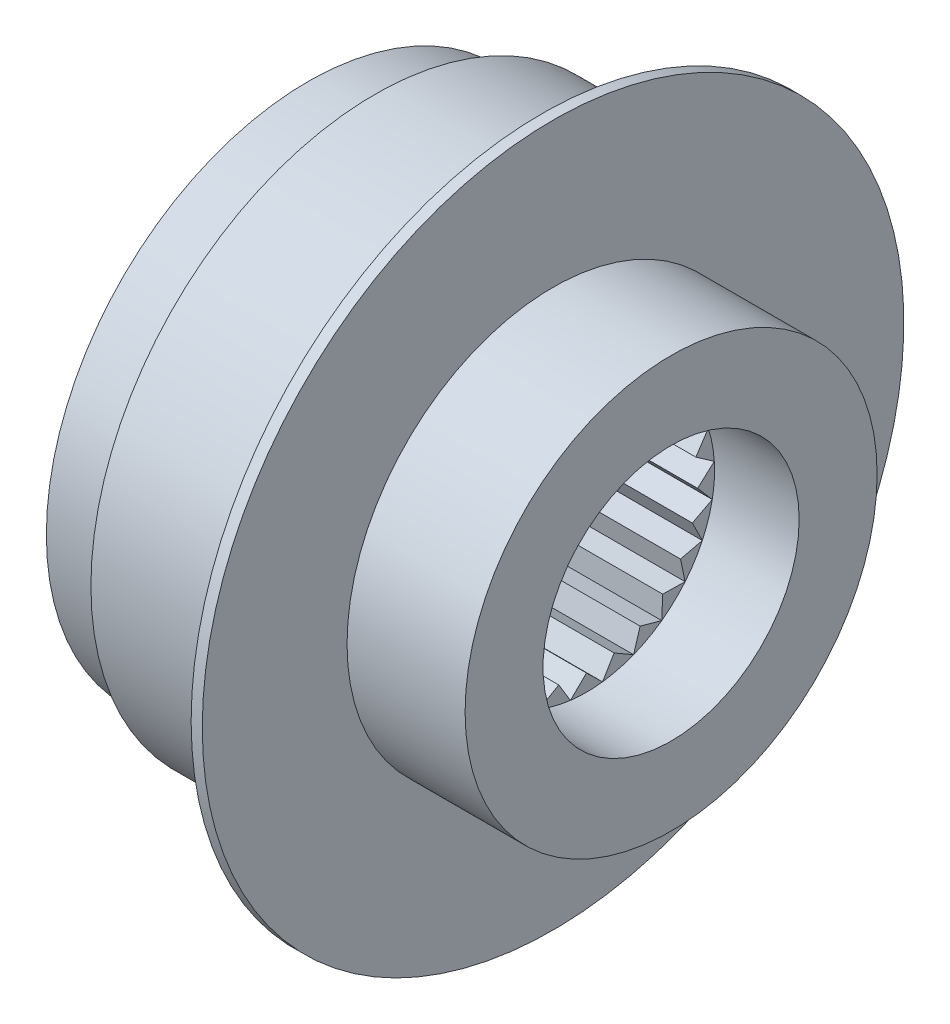
from build123d import *

# Parameters (mm, degrees)
SKETCH2_R          = 3.96875
CUT_EXTRUDE1_DEPTH = 6.35
CUT_EXTRUDE2_START = -41.402
CUT_EXTRUDE2_DEPTH = 31.75
SKETCH3_4_R        = 14.605
CUT_EXTRUDE3_DEPTH = 9.652


with BuildPart() as part:
    # Sketch1 → Revolve1 (revolve)
    with BuildSketch(Plane(origin=(0, 0, 0), x_dir=(1, 0, 0), z_dir=(0, 1, 0))):
        Polygon((-20.701, -12.7), (-20.701, -29.845), (-13.081, -29.845), (-13.081, -32.385), (5.969, -32.385), (5.969, -40.005), (7.239, -40.005), (7.239, -23.495), (20.701, -23.495), (20.701, -12.7), align=None)
    revolve(axis=Axis((-34.012862719, 0, 0), (1, 0, 0)))

    # Sketch2 → Cut-Extrude1 (cut)
    with BuildSketch(Plane(origin=(-20.701, 0, 0), x_dir=(0, 0, -1), z_dir=(1, 0, 0))):
        with Locations((22.225, 0)):
            Circle(SKETCH2_R)
        with Locations((-11.1125, -19.247414599)):
            Circle(SKETCH2_R)
        with Locations((-11.1125, 19.247414599)):
            Circle(SKETCH2_R)
    extrude(amount=CUT_EXTRUDE1_DEPTH, mode=Mode.SUBTRACT)

    # Sketch3 → Cut-Extrude2 (cut)
    with BuildSketch(Plane(origin=(20.701, 0, 0), x_dir=(0, 0, -1), z_dir=(1, 0, 0)).offset(CUT_EXTRUDE2_START)):
        with BuildLine():
            Line((-13.214999101, -6.218506553), (-10.722964654, -6.805000296))
            ThreePointArc((-10.722964654, -6.805000296), (-11.491303566, -5.407397003), (-12.078417757, -3.924515829))
            Line((-12.078417757, -3.924515829), (-13.214999101, -6.218506553))
        make_face()
        with BuildLine():
            Line((-14.346305297, -2.7367041), (-12.078417757, -3.924515829))
            ThreePointArc((-12.078417757, -3.924515829), (-12.475048084, -2.379742695), (-12.674939451, -0.797439598))
            Line((-12.674939451, -0.797439598), (-14.346305297, -2.7367041))
        make_face()
        with BuildLine():
            Line((-14.576180369, 0.917055538), (-12.674939451, -0.797439598))
            ThreePointArc((-12.674939451, -0.797439598), (-12.674939451, 0.797439598), (-12.475048084, 2.379742695))
            Line((-12.475048084, 2.379742695), (-14.576180369, 0.917055538))
        make_face()
        with BuildLine():
            Line((-13.89018042, 4.513193203), (-12.475048084, 2.379742695))
            ThreePointArc((-12.475048084, 2.379742695), (-12.078417757, 3.924515829), (-11.491303566, 5.407397003))
            Line((-11.491303566, 5.407397003), (-13.89018042, 4.513193203))
        make_face()
        with BuildLine():
            Line((-12.331409352, 7.825750341), (-11.491303566, 5.407397003))
            ThreePointArc((-11.491303566, 5.407397003), (-10.722964654, 6.805000296), (-9.785518183, 8.09528467))
            Line((-9.785518183, 8.09528467), (-12.331409352, 7.825750341))
        make_face()
        with BuildLine():
            Line((-9.997810482, 10.646586803), (-9.785518183, 8.09528467))
            ThreePointArc((-9.785518183, 8.09528467), (-8.693748245, 9.257901568), (-7.464872704, 10.274515829))
            Line((-7.464872704, 10.274515829), (-9.997810482, 10.646586803))
        make_face()
        with BuildLine():
            Line((-7.03601241, 12.798459062), (-7.464872704, 10.274515829))
            ThreePointArc((-7.464872704, 10.274515829), (-6.118271661, 11.129094837), (-4.675181819, 11.808161371))
            Line((-4.675181819, 11.808161371), (-7.03601241, 12.798459062))
        make_face()
        with BuildLine():
            Line((-3.632115802, 14.146157068), (-4.675181819, 11.808161371))
            ThreePointArc((-4.675181819, 11.808161371), (-3.158361567, 12.301006146), (-1.591732066, 12.599856707))
            Line((-1.591732066, 12.599856707), (-3.632115802, 14.146157068))
        make_face()
        with BuildLine():
            ThreePointArc((-1.591732066, 12.599856707), (0, 12.7), (1.591732066, 12.599856707))
            Line((1.591732066, 12.599856707), (0, 14.605))
            Line((0, 14.605), (-1.591732066, 12.599856707))
        make_face()
        with BuildLine():
            ThreePointArc((1.591732066, 12.599856707), (3.158361567, 12.301006146), (4.675181819, 11.808161371))
            Line((4.675181819, 11.808161371), (3.632115802, 14.146157068))
            Line((3.632115802, 14.146157068), (1.591732066, 12.599856707))
        make_face()
        with BuildLine():
            ThreePointArc((4.675181819, 11.808161371), (6.118271661, 11.129094837), (7.464872704, 10.274515829))
            Line((7.464872704, 10.274515829), (7.03601241, 12.798459062))
            Line((7.03601241, 12.798459062), (4.675181819, 11.808161371))
        make_face()
        with BuildLine():
            ThreePointArc((7.464872704, 10.274515829), (8.693748245, 9.257901568), (9.785518183, 8.09528467))
            Line((9.785518183, 8.09528467), (9.997810482, 10.646586803))
            Line((9.997810482, 10.646586803), (7.464872704, 10.274515829))
        make_face()
        with BuildLine():
            ThreePointArc((9.785518183, 8.09528467), (10.722964654, 6.805000296), (11.491303566, 5.407397003))
            Line((11.491303566, 5.407397003), (12.331409352, 7.825750341))
            Line((12.331409352, 7.825750341), (9.785518183, 8.09528467))
        make_face()
        with BuildLine():
            ThreePointArc((11.491303566, 5.407397003), (12.078417757, 3.924515829), (12.475048084, 2.379742695))
            Line((12.475048084, 2.379742695), (13.89018042, 4.513193203))
            Line((13.89018042, 4.513193203), (11.491303566, 5.407397003))
        make_face()
        with BuildLine():
            ThreePointArc((12.7, 0), (12.693733317, -0.39891664), (12.674939451, -0.797439598))
            Line((12.674939451, -0.797439598), (14.576180369, 0.917055538))
            Line((14.576180369, 0.917055538), (12.475048084, 2.379742695))
            ThreePointArc((12.475048084, 2.379742695), (12.64363695, 1.195175579), (12.7, 0))
        make_face()
        with BuildLine():
            ThreePointArc((12.674939451, -0.797439598), (12.475048084, -2.379742695), (12.078417757, -3.924515829))
            Line((12.078417757, -3.924515829), (14.346305297, -2.7367041))
            Line((14.346305297, -2.7367041), (12.674939451, -0.797439598))
        make_face()
        with BuildLine():
            ThreePointArc((12.078417757, -3.924515829), (11.491303566, -5.407397003), (10.722964654, -6.805000296))
            Line((10.722964654, -6.805000296), (13.214999101, -6.218506553))
            Line((13.214999101, -6.218506553), (12.078417757, -3.924515829))
        make_face()
        with BuildLine():
            ThreePointArc((10.722964654, -6.805000296), (9.785518183, -8.09528467), (8.693748245, -9.257901568))
            Line((8.693748245, -9.257901568), (11.253345911, -9.30957737))
            Line((11.253345911, -9.30957737), (10.722964654, -6.805000296))
        make_face()
        with BuildLine():
            ThreePointArc((8.693748245, -9.257901568), (7.464872704, -10.274515829), (6.118271661, -11.129094837))
            Line((6.118271661, -11.129094837), (8.58460361, -11.815693203))
            Line((8.58460361, -11.815693203), (8.693748245, -9.257901568))
        make_face()
        with BuildLine():
            Line((1.830491876, -14.489835213), (3.158361567, -12.301006146))
            ThreePointArc((3.158361567, -12.301006146), (1.591732066, -12.599856707), (0, -12.7))
            Line((0, -12.7), (1.830491876, -14.489835213))
        make_face()
        with BuildLine():
            Line((-1.830491876, -14.489835213), (0, -12.7))
            ThreePointArc((0, -12.7), (-1.591732066, -12.599856707), (-3.158361567, -12.301006146))
            Line((-3.158361567, -12.301006146), (-1.830491876, -14.489835213))
        make_face()
        with BuildLine():
            Line((-5.376459092, -13.579385576), (-3.158361567, -12.301006146))
            ThreePointArc((-3.158361567, -12.301006146), (-4.675181819, -11.808161371), (-6.118271661, -11.129094837))
            Line((-6.118271661, -11.129094837), (-5.376459092, -13.579385576))
        make_face()
        with BuildLine():
            Line((-8.58460361, -11.815693203), (-6.118271661, -11.129094837))
            ThreePointArc((-6.118271661, -11.129094837), (-7.464872704, -10.274515829), (-8.693748245, -9.257901568))
            Line((-8.693748245, -9.257901568), (-8.58460361, -11.815693203))
        make_face()
        with BuildLine():
            Line((-11.253345911, -9.30957737), (-8.693748245, -9.257901568))
            ThreePointArc((-8.693748245, -9.257901568), (-9.785518183, -8.09528467), (-10.722964654, -6.805000296))
            Line((-10.722964654, -6.805000296), (-11.253345911, -9.30957737))
        make_face()
        with BuildLine():
            Line((6.118271661, -11.129094837), (5.376459092, -13.579385576))
            Line((5.376459092, -13.579385576), (3.158361567, -12.301006146))
            ThreePointArc((3.158361567, -12.301006146), (4.675181819, -11.808161371), (6.118271661, -11.129094837))
        make_face()
    extrude(amount=CUT_EXTRUDE2_DEPTH, mode=Mode.SUBTRACT)

    # Sketch3_4 → Cut-Extrude3 (cut)
    with BuildSketch(Plane(origin=(20.701, 0, 0), x_dir=(0, 0, -1), z_dir=(1, 0, 0))):
        Circle(SKETCH3_4_R)
    extrude(amount=-CUT_EXTRUDE3_DEPTH, mode=Mode.SUBTRACT)


solid = part.part
